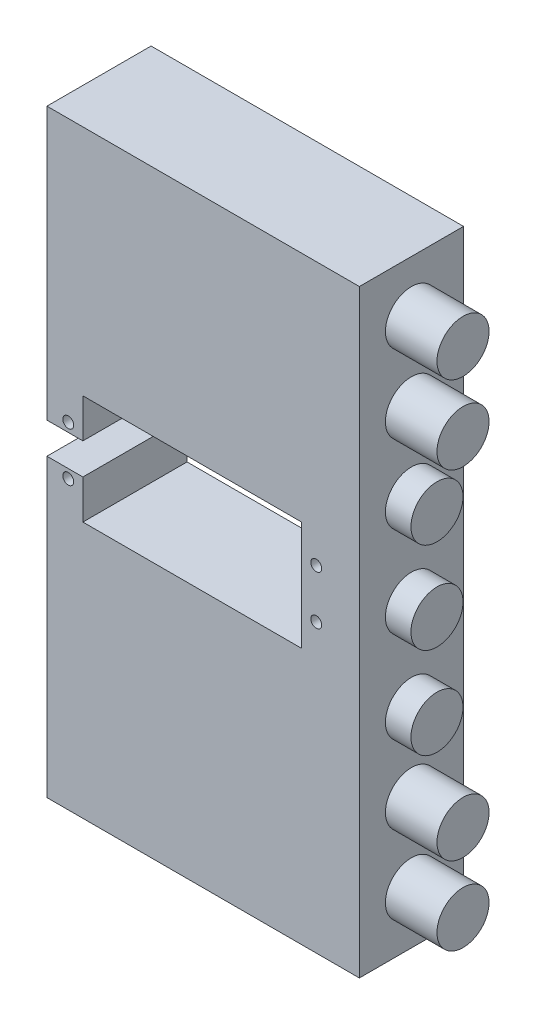
from build123d import *

# Parameters (mm, degrees)
SKETCH_5_W          = 60
SKETCH_5_H          = 115
EXTRUDE_2_DEPTH     = 20
SKETCH_1_R          = 1.05
CUT_EXTRUDE_4_DEPTH = 20
SKETCH_6_R          = 5
EXTRUDE_3_DEPTH     = 10
SKETCH_7_R          = 5
EXTRUDE_4_DEPTH     = 5


with BuildPart() as part:
    # 草圖5 → 填料-伸長2 (new body)
    with BuildSketch(Plane.XY):
        with Locations((85.095319229, -5.277137892)):
            Rectangle(SKETCH_5_W, SKETCH_5_H)
    extrude(amount=EXTRUDE_2_DEPTH)

    # 草圖1 → 除料-伸長4 (cut)
    with BuildSketch(Plane.XY):
        with Locations((59.19, 1.7)):
            Circle(SKETCH_1_R)
        with Locations((106.81, 1.7)):
            Circle(SKETCH_1_R)
        with Locations((106.81, -7.7)):
            Circle(SKETCH_1_R)
        with Locations((59.19, -7.7)):
            Circle(SKETCH_1_R)
        Polygon((55, -3), (55, 0), (62, 0), (62, 7.5), (104, 7.5), (104, -13.5), (62, -13.5), (62, -6), (55, -6), align=None)
    extrude(amount=CUT_EXTRUDE_4_DEPTH, mode=Mode.SUBTRACT)

    # 草圖6 → 填料-伸長3 (add)
    with BuildSketch(Plane(origin=(115, 0, 0), x_dir=(0, 0, -1), z_dir=(1, 0, 0))):
        with Locations((-10, 42.222862108)):
            Circle(SKETCH_6_R)
        with Locations((-10, 27.222862108)):
            Circle(SKETCH_6_R)
        with Locations((-10, -37.777137892)):
            Circle(SKETCH_6_R)
        with Locations((-10, -52.777137892)):
            Circle(SKETCH_6_R)
    extrude(amount=EXTRUDE_3_DEPTH)

    # 草圖7 → 填料-伸長4 (add)
    with BuildSketch(Plane(origin=(115, 0, 0), x_dir=(0, 0, -1), z_dir=(1, 0, 0))):
        with Locations((-10, 12.222862108)):
            Circle(SKETCH_7_R)
        with Locations((-10, -5.277137892)):
            Circle(SKETCH_7_R)
        with Locations((-10, -22.777137892)):
            Circle(SKETCH_7_R)
    extrude(amount=EXTRUDE_4_DEPTH)


solid = part.part
